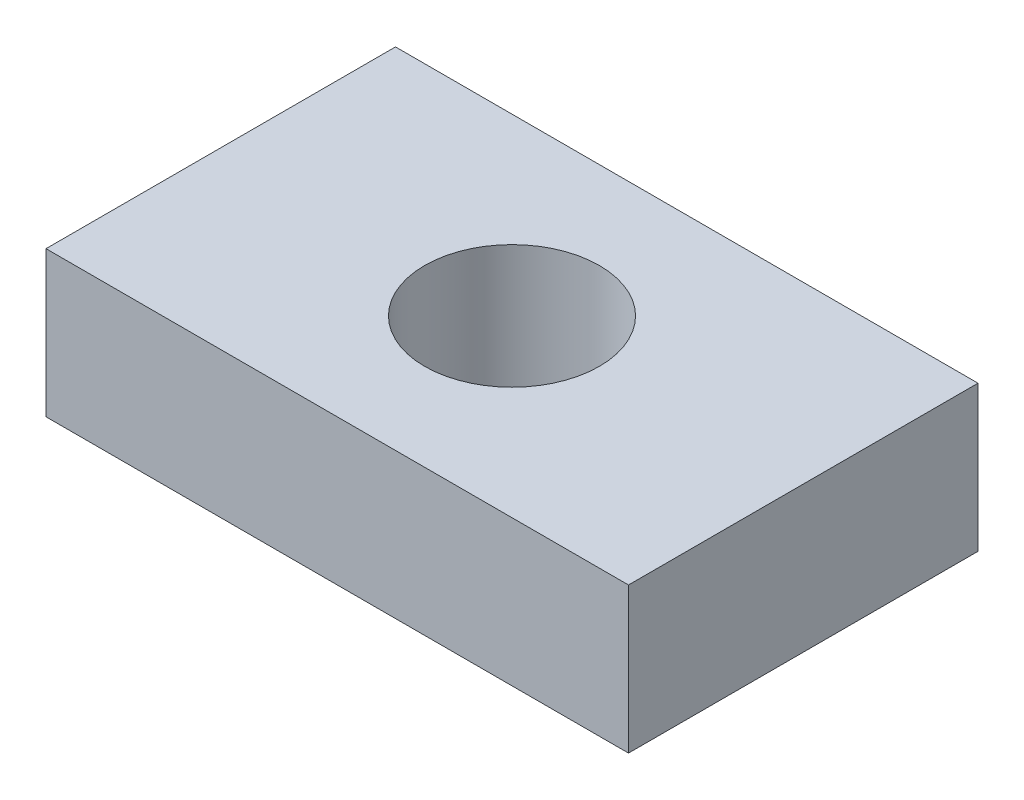
from build123d import *

# Parameters (mm, degrees)
SKETCH1_W           = 10
SKETCH1_H           = 6
SKETCH1_R           = 1.5
BOSS_EXTRUDE1_DEPTH = 2.5


with BuildPart() as part:
    # Sketch1 → Boss-Extrude1 (new body)
    with BuildSketch(Plane(origin=(0, 0, 0), x_dir=(1, 0, 0), z_dir=(0, 1, 0))):
        Rectangle(SKETCH1_W, SKETCH1_H)
        Circle(SKETCH1_R, mode=Mode.SUBTRACT)
    extrude(amount=BOSS_EXTRUDE1_DEPTH)


solid = part.part
